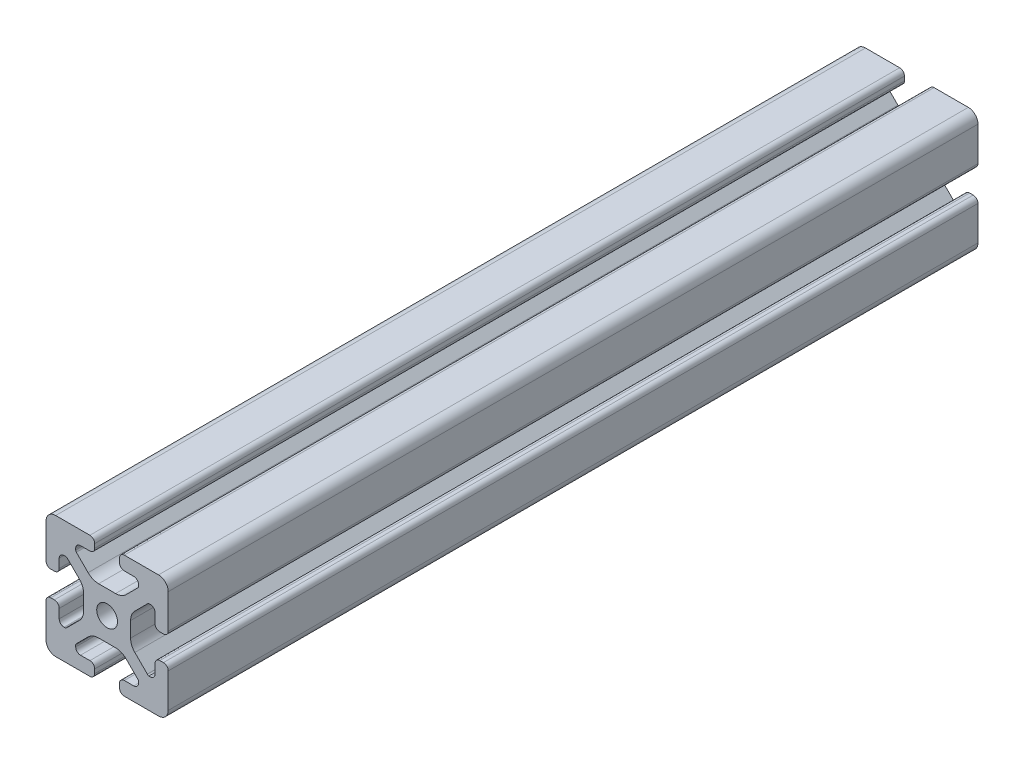
from build123d import *

# Parameters (mm, degrees)
SKETCH1_R      = 3.4
EXTRUDE1_DEPTH = 265


with BuildPart() as part:
    # Sketch1 → Extrude1 (new body)
    with BuildSketch(Plane.XY):
        with BuildLine():
            Line((-8.715, -15.524615034), (-5.63, -15.524615034))
            ThreePointArc((-5.63, -15.524615034), (-4.519842354, -15.984457388), (-4.06, -17.094615034))
            Line((-4.06, -17.094615034), (-4.06, -18.43))
            ThreePointArc((-4.06, -18.43), (-4.519842354, -19.540157646), (-5.63, -20))
            Line((-5.63, -20), (-16.674615034, -20))
            ThreePointArc((-16.674615034, -20), (-18.951578385, -19.194274381), (-20, -17.018368134))
            Line((-20, -17.018368134), (-20, -5.757918808))
            ThreePointArc((-20, -5.757918808), (-19.564709668, -4.603883664), (-18.43, -4.120449326))
            Line((-18.43, -4.120449326), (-17.25, -4.120449326))
            ThreePointArc((-17.25, -4.120449326), (-16.115287682, -4.60388249), (-15.67999625, -5.757919334))
            Line((-15.67999625, -5.757919334), (-15.67999625, -8.715399492))
            ThreePointArc((-15.67999625, -8.715399492), (-15.220153896, -9.825557139), (-14.10999625, -10.285399492))
            Line((-14.10999625, -10.285399492), (-13.816898819, -10.285399492))
            ThreePointArc((-13.816898819, -10.285399492), (-13.526061711, -10.227547119), (-13.279501941, -10.062800646))
            Line((-13.279501941, -10.062800646), (-9.076242789, -5.859541495))
            ThreePointArc((-9.076242789, -5.859541495), (-8.046572221, -4.318530588), (-7.685, -2.500784284))
            Line((-7.685, -2.500784284), (-7.685, 2.500784284))
            ThreePointArc((-7.685, 2.500784284), (-8.046572221, 4.318530588), (-9.076242789, 5.859541495))
            Line((-9.076242789, 5.859541495), (-13.040489136, 9.823787841))
            ThreePointArc((-13.040489136, 9.823787841), (-13.354224618, 10.012729352), (-13.71989919, 10.033001362))
            Line((-13.71989919, 10.033001362), (-14.05520779, 10.044710596))
            ThreePointArc((-14.05520779, 10.044710596), (-15.200613642, 9.605030484), (-15.68, 8.475666998))
            Line((-15.68, 8.475666998), (-15.68, 5.572979049))
            ThreePointArc((-15.68, 5.572979049), (-16.139842354, 4.462821403), (-17.25, 4.002979049))
            Line((-17.25, 4.002979049), (-18.43, 4.002979049))
            ThreePointArc((-18.43, 4.002979049), (-19.540157646, 4.462821403), (-20, 5.572979049))
            Line((-20, 5.572979049), (-20, 13.004526564))
            Line((-20, 13.004526564), (-20, 16.83))
            ThreePointArc((-20, 16.83), (-19.071528496, 19.071528496), (-16.83, 20))
            Line((-16.83, 20), (-5.63, 20))
            ThreePointArc((-5.63, 20), (-4.519842354, 19.540157646), (-4.06, 18.43))
            Line((-4.06, 18.43), (-4.06, 17.094615034))
            ThreePointArc((-4.06, 17.094615034), (-4.519842354, 15.984457388), (-5.63, 15.524615034))
            Line((-5.63, 15.524615034), (-8.715, 15.524615034))
            ThreePointArc((-8.715, 15.524615034), (-9.825157646, 15.06477268), (-10.285, 13.954615034))
            Line((-10.285, 13.954615034), (-10.285, 13.492503602))
            ThreePointArc((-10.285, 13.492503602), (-10.227148445, 13.201664194), (-10.062401154, 12.955102448))
            Line((-10.062401154, 12.955102448), (-6.217092793, 9.109794088))
            ThreePointArc((-6.217092793, 9.109794088), (-4.63891877, 8.055291919), (-2.777335583, 7.685))
            Line((-2.777335583, 7.685), (2.777335583, 7.685))
            ThreePointArc((2.777335583, 7.685), (4.63891877, 8.055291919), (6.217092793, 9.109794088))
            Line((6.217092793, 9.109794088), (10.062401154, 12.955102448))
            ThreePointArc((10.062401154, 12.955102448), (10.227148445, 13.201664194), (10.285, 13.492503602))
            Line((10.285, 13.492503602), (10.285, 13.954615034))
            ThreePointArc((10.285, 13.954615034), (9.825157646, 15.06477268), (8.715, 15.524615034))
            Line((8.715, 15.524615034), (5.63, 15.524615034))
            ThreePointArc((5.63, 15.524615034), (4.519842354, 15.984457388), (4.06, 17.094615034))
            Line((4.06, 17.094615034), (4.06, 18.43))
            ThreePointArc((4.06, 18.43), (4.519842354, 19.540157646), (5.63, 20))
            Line((5.63, 20), (12.979635074, 20))
            Line((12.979635074, 20), (16.83, 20))
            ThreePointArc((16.83, 20), (19.071528496, 19.071528496), (20, 16.83))
            Line((20, 16.83), (20, 13.001098436))
            Line((20, 13.001098436), (20, 5.63))
            ThreePointArc((20, 5.63), (19.540157461, 4.519842693), (18.43, 4.060000526))
            Line((18.43, 4.060000526), (17.24999625, 4.060000526))
            ThreePointArc((17.24999625, 4.060000526), (16.139838603, 4.519842879), (15.67999625, 5.630000526))
            Line((15.67999625, 5.630000526), (15.67999625, 8.715399492))
            ThreePointArc((15.67999625, 8.715399492), (15.220153896, 9.825557139), (14.10999625, 10.285399492))
            Line((14.10999625, 10.285399492), (13.816903094, 10.285399492))
            ThreePointArc((13.816903094, 10.285399492), (13.526063686, 10.227547937), (13.279501941, 10.062800646))
            Line((13.279501941, 10.062800646), (9.076242789, 5.859541495))
            ThreePointArc((9.076242789, 5.859541495), (8.046572221, 4.318530588), (7.685, 2.500784284))
            Line((7.685, 2.500784284), (7.685, -2.500784284))
            ThreePointArc((7.685, -2.500784284), (8.046572221, -4.318530588), (9.076242789, -5.859541495))
            Line((9.076242789, -5.859541495), (13.163657296, -9.946956002))
            ThreePointArc((13.163657296, -9.946956002), (13.35903797, -10.160433474), (13.6200547, -10.285399492))
            Line((13.6200547, -10.285399492), (14.10999625, -10.285399492))
            ThreePointArc((14.10999625, -10.285399492), (15.220153896, -9.825557139), (15.67999625, -8.715399492))
            Line((15.67999625, -8.715399492), (15.67999625, -5.630000526))
            ThreePointArc((15.67999625, -5.630000526), (16.139838603, -4.519842879), (17.24999625, -4.060000526))
            Line((17.24999625, -4.060000526), (18.43, -4.060000526))
            ThreePointArc((18.43, -4.060000526), (19.540157461, -4.519842693), (20, -5.63))
            Line((20, -5.63), (20, -16.83))
            ThreePointArc((20, -16.83), (19.071528496, -19.071528496), (16.83, -20))
            Line((16.83, -20), (13, -20))
            Line((13, -20), (5.63, -20))
            ThreePointArc((5.63, -20), (4.519842354, -19.540157646), (4.06, -18.43))
            Line((4.06, -18.43), (4.06, -17.094615034))
            ThreePointArc((4.06, -17.094615034), (4.519842354, -15.984457388), (5.63, -15.524615034))
            Line((5.63, -15.524615034), (8.715, -15.524615034))
            ThreePointArc((8.715, -15.524615034), (9.825157646, -15.06477268), (10.285, -13.954615034))
            Line((10.285, -13.954615034), (10.285, -13.492503602))
            ThreePointArc((10.285, -13.492503602), (10.227148445, -13.201664194), (10.062401154, -12.955102448))
            Line((10.062401154, -12.955102448), (6.217092793, -9.109794088))
            ThreePointArc((6.217092793, -9.109794088), (4.63891877, -8.055291919), (2.777335583, -7.685))
            Line((2.777335583, -7.685), (-2.777335583, -7.685))
            ThreePointArc((-2.777335583, -7.685), (-4.63891877, -8.055291919), (-6.217092793, -9.109794088))
            Line((-6.217092793, -9.109794088), (-10.062401154, -12.955102448))
            ThreePointArc((-10.062401154, -12.955102448), (-10.227148445, -13.201664194), (-10.285, -13.492503602))
            Line((-10.285, -13.492503602), (-10.285, -13.954615034))
            ThreePointArc((-10.285, -13.954615034), (-9.825157646, -15.06477268), (-8.715, -15.524615034))
        make_face()
        Circle(SKETCH1_R, mode=Mode.SUBTRACT)
    extrude(amount=-EXTRUDE1_DEPTH)


solid = part.part
